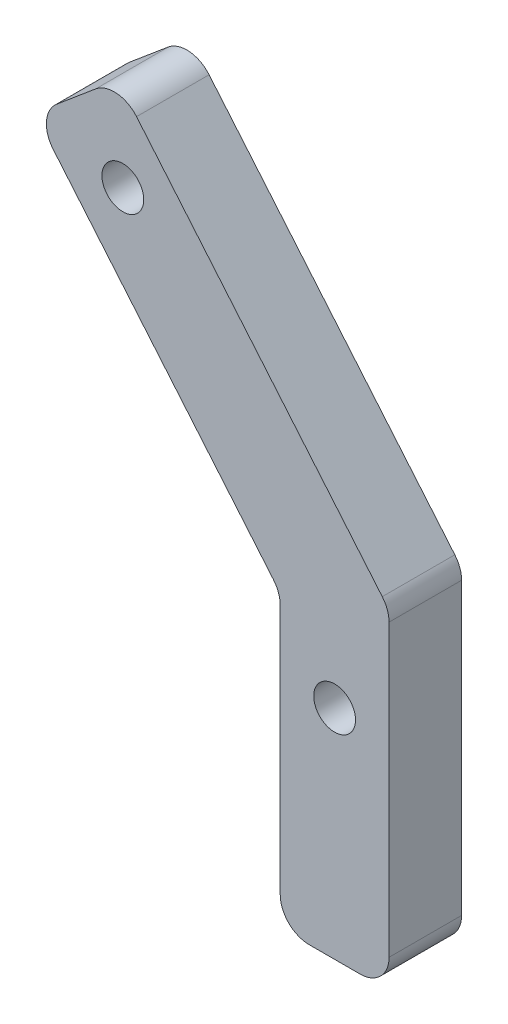
from build123d import *

# Parameters (mm, degrees)
BOSS_EXTRUDE1_DEPTH       = 6.35
FILLET1_R                 = 2.54
F_6_CLEARANCE_HOLE1_D     = 3.6576
F_6_CLEARANCE_HOLE1_DEPTH = 10.16
F_6_CLEARANCE_HOLE1_TIP   = 1.0988539


with BuildPart() as part:
    # Sketch1 → Boss-Extrude1 (new body)
    with BuildSketch(Plane.XY):
        Polygon((0, 0), (7.296573321, 6.122551982), (31.02898218, -22.160631536), (31.02898218, -51.027448018), (21.50398218, -51.027448018), (21.50398218, -25.627448018), align=None)
    extrude(amount=BOSS_EXTRUDE1_DEPTH)

    # Fillet1
    fillet1_edges = [part.edges().sort_by_distance(p)[0] for p in [
        (0, 0, 3.175),
        (7.296573321, 6.122551982, 3.175),
        (31.02898218, -22.160631536, 3.175),
        (31.02898218, -51.027448018, 3.175),
        (21.50398218, -51.027448018, 3.175),
        (21.50398218, -25.627448018, 3.175),
    ]]
    fillet(fillet1_edges, radius=FILLET1_R)

    # #6 Clearance Hole1
    with Locations(Plane.XY.offset(6.35)):
        with Locations((7.729987982, -1.803106223), (26.26648218, -31.977448018)):
            Hole(F_6_CLEARANCE_HOLE1_D / 2, depth=F_6_CLEARANCE_HOLE1_DEPTH)
            with Locations((0, 0, -(F_6_CLEARANCE_HOLE1_DEPTH + F_6_CLEARANCE_HOLE1_TIP / 2))):  # 118° drill point
                Cone(0, F_6_CLEARANCE_HOLE1_D / 2, F_6_CLEARANCE_HOLE1_TIP, mode=Mode.SUBTRACT)


solid = part.part
